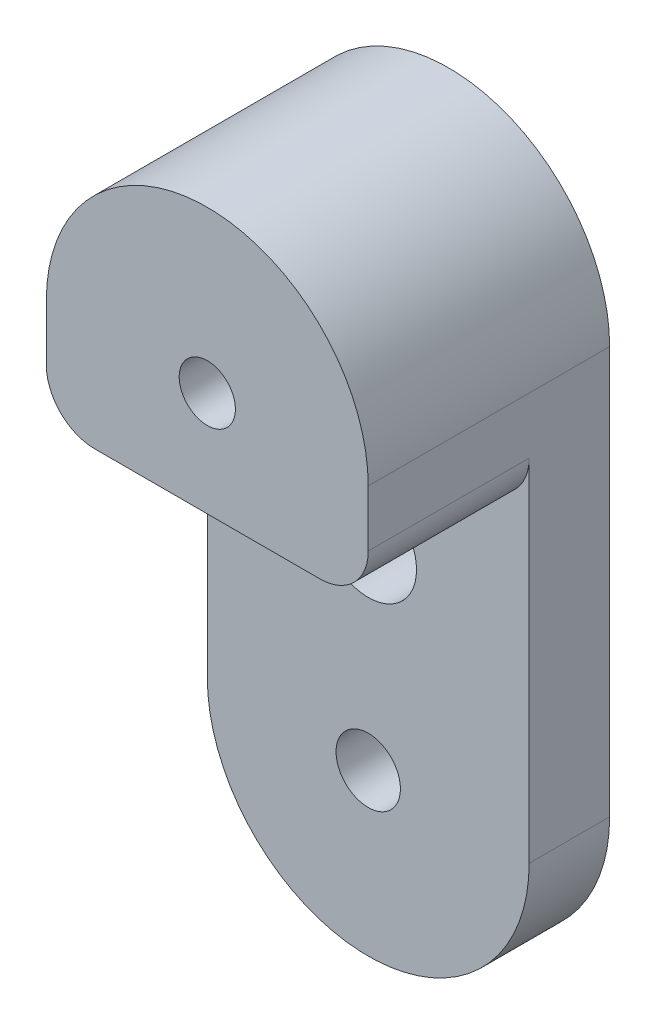
from build123d import *

# Parameters (mm, degrees)
SKETCH1_R           = 2
SKETCH1_R_2         = 3
BOSS_EXTRUDE1_DEPTH = 5
SKETCH1_3_R         = 1.74625
BOSS_EXTRUDE2_DEPTH = 15
FILLET1_R           = 3


with BuildPart() as part:
    # Sketch1 → Boss-Extrude1 (new body)
    with BuildSketch(Plane.XY):
        with BuildLine():
            Line((10, -25.3), (10, -6.5))
            Line((10, -6.5), (-10, -6.5))
            Line((-10, -6.5), (-10, -25.3))
            ThreePointArc((-10, -25.3), (0, -35.3), (10, -25.3))
        make_face()
        with Locations((0, -25.3)):
            Circle(SKETCH1_R, mode=Mode.SUBTRACT)
        with Locations((0, -13)):
            Circle(SKETCH1_R_2, mode=Mode.SUBTRACT)
    extrude(amount=BOSS_EXTRUDE1_DEPTH)

    # Sketch1_3 → Boss-Extrude2 (add)
    with BuildSketch(Plane.XY):
        with BuildLine():
            Line((10, -6.5), (10, 0))
            ThreePointArc((10, 0), (0, 10), (-10, 0))
            Line((-10, 0), (-10, -6.5))
            Line((-10, -6.5), (10, -6.5))
        make_face()
        Circle(SKETCH1_3_R, mode=Mode.SUBTRACT)
    extrude(amount=BOSS_EXTRUDE2_DEPTH)

    # Fillet1
    fillet1_edges = [part.edges().sort_by_distance(p)[0] for p in [
        (10, -6.5, 10),
        (-10, -6.5, 10),
    ]]
    fillet(fillet1_edges, radius=FILLET1_R)


solid = part.part
